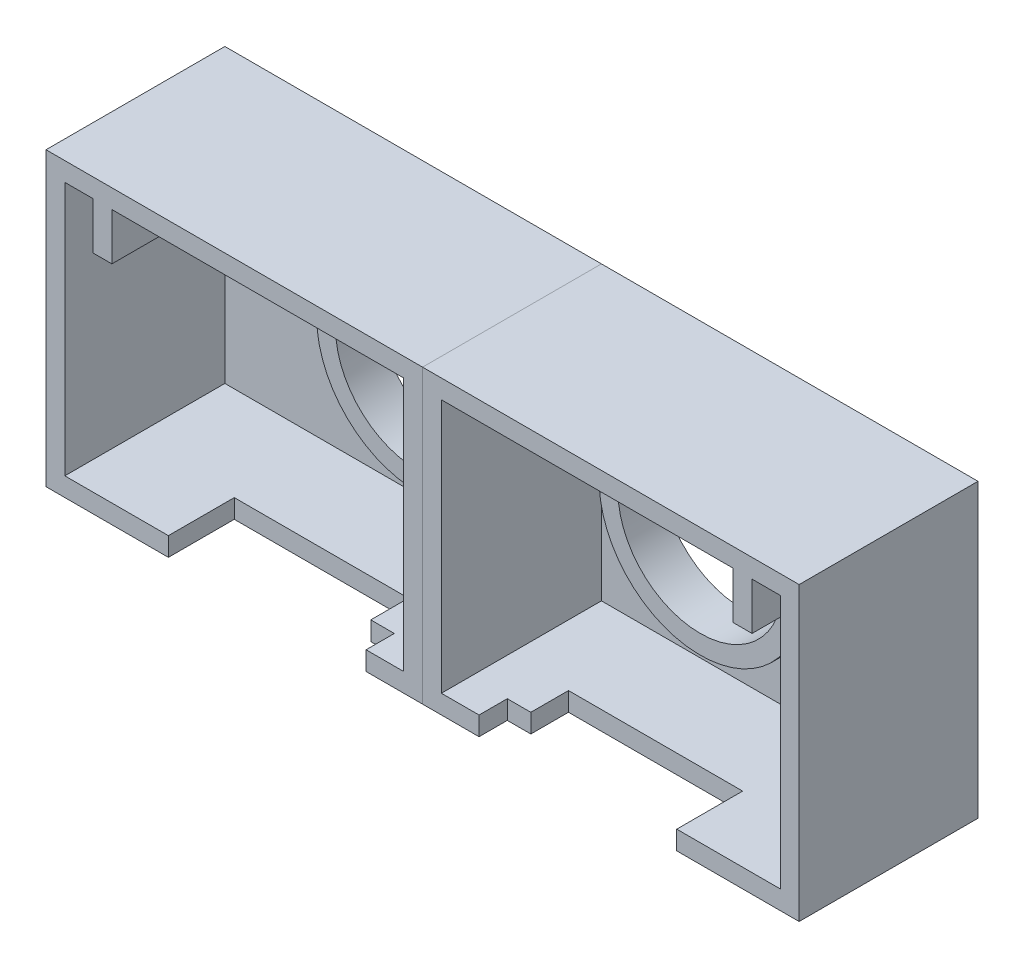
from build123d import *

# Parameters (mm, degrees)
SKETCH1_W                      = 40
SKETCH1_H                      = 31
SKETCH1_R                      = 8.75
BOSS_EXTRUDE1_DEPTH            = 19
SHELL1_T                       = -2
SKETCH2_R                      = 10.75
SKETCH2_R_2                    = 8.75
CUT_EXTRUDE1_DEPTH             = 14.5
SKETCH3_W                      = 2
SKETCH3_H                      = 5
BOSS_EXTRUDE2_DEPTH            = 17
SKETCH8_W                      = 7
SKETCH8_H                      = 7
BOSS_EXTRUDE3_DEPTH            = 3
CBORE_FOR_M3_SHCS1_D           = 3.4
CBORE_FOR_M3_SHCS1_CBORE_D     = 6.5
CBORE_FOR_M3_SHCS1_CBORE_DEPTH = 3
CUT_EXTRUDE3_REACH             = 46.125


with BuildPart() as part:
    # Sketch1 → Boss-Extrude1 (new body)
    with BuildSketch(Plane.XY):
        with Locations((-5, 0)):
            Rectangle(SKETCH1_W, SKETCH1_H)
        Circle(SKETCH1_R, mode=Mode.SUBTRACT)
    extrude(amount=-BOSS_EXTRUDE1_DEPTH)

    # Shell1
    shell1_openings = [part.faces().sort_by_distance(p)[0] for p in [
        (-5, -14.993936763, 0),
    ]]
    offset(amount=SHELL1_T, openings=shell1_openings, kind=Kind.INTERSECTION)

    # Sketch2 → Cut-Extrude1 (cut)
    with BuildSketch(Plane.XY):
        with Locations(Location((0, 0, 0), (0, 0, 180))):
            Circle(SKETCH2_R)
        Circle(SKETCH2_R_2, mode=Mode.SUBTRACT)
    extrude(amount=-CUT_EXTRUDE1_DEPTH, mode=Mode.SUBTRACT)

    # Sketch3 → Boss-Extrude2 (add)
    with BuildSketch(Plane.XY.offset(-17)):
        with Locations((-19, 11)):
            Rectangle(SKETCH3_W, SKETCH3_H)
    extrude(amount=BOSS_EXTRUDE2_DEPTH)

    # Sketch8 → Boss-Extrude3 (add)
    with BuildSketch(Plane.XY.offset(-17)):
        with Locations((-14.5, 10)):
            Rectangle(SKETCH8_W, SKETCH8_H)
    extrude(amount=BOSS_EXTRUDE3_DEPTH)

    # CBORE for M3 SHCS1 (through all)
    with Locations(Plane(origin=(0, 0, -19), x_dir=(-1, 0, 0), z_dir=(0, 0, -1))):
        with Locations((15, 10.5)):
            CounterBoreHole(CBORE_FOR_M3_SHCS1_D / 2, CBORE_FOR_M3_SHCS1_CBORE_D / 2, CBORE_FOR_M3_SHCS1_CBORE_DEPTH)

    # Sketch9 → Cut-Extrude3 (cut, up to next)
    with BuildSketch(Plane.XZ.offset(15.5), mode=Mode.PRIVATE) as cut_extrude3_sk1:
        Polygon((-12, 0), (6.5, 0), (9, 0), (9, -3), (6.5, -3), (6.5, -7), (-12, -7), align=None)
    cut_extrude3_tool1 = extrude(cut_extrude3_sk1.sketch, amount=-CUT_EXTRUDE3_REACH, mode=Mode.PRIVATE) & part.part
    add(cut_extrude3_tool1.solids().sort_by_distance((-2.175182, -15.5, -3.390511))[0], mode=Mode.SUBTRACT)


with BuildPart() as body_2:
    # Mirror2: mirrored copy
    add(part.part.mirror(Plane(origin=(15, -15.5, -19), x_dir=(0, 0, 1), z_dir=(1, 0, 0))))


solid = Compound([part.part, body_2.part])
